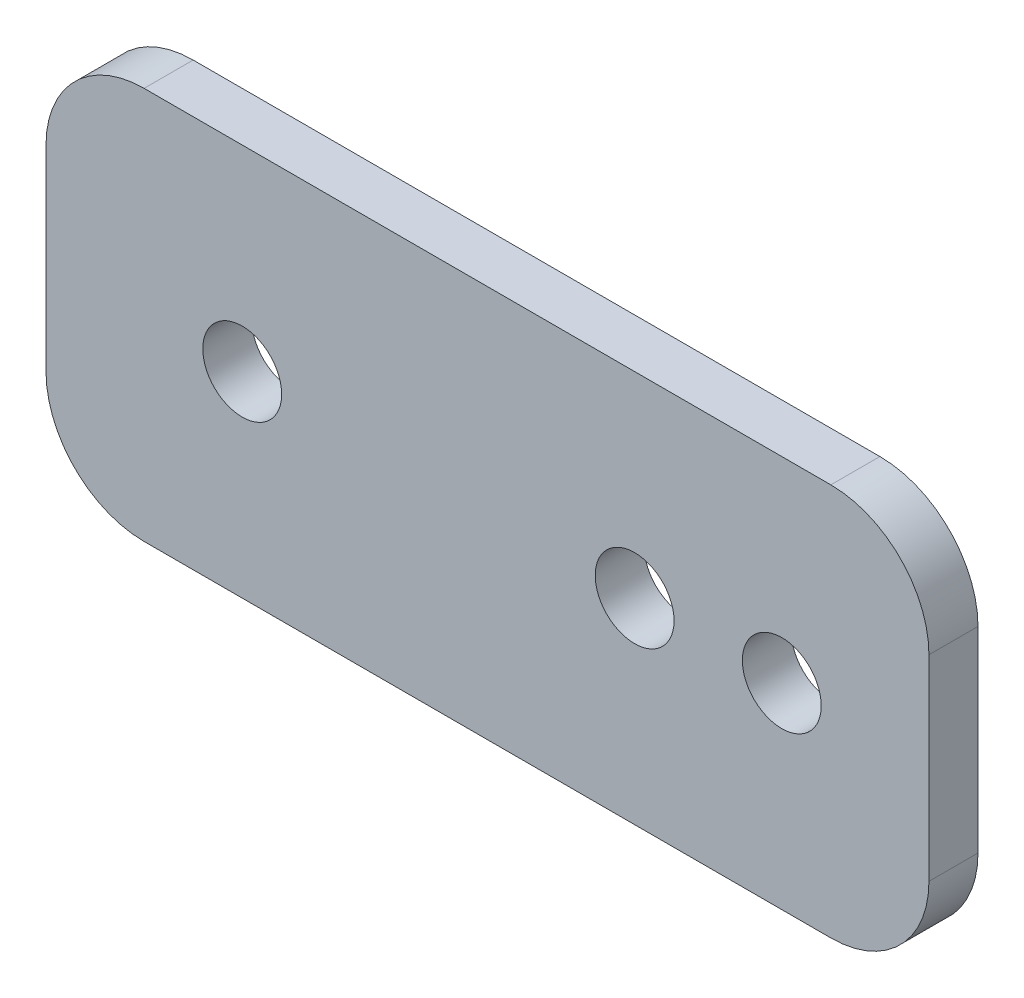
from build123d import *

# Parameters (mm, degrees)
SKETCH1_W           = 57.15
SKETCH1_H           = 25.4
SKETCH1_R           = 2.5527
BOSS_EXTRUDE1_DEPTH = 3.175
FILLET1_R           = 6.35


with BuildPart() as part:
    # Sketch1 → Boss-Extrude1 (new body)
    with BuildSketch(Plane.XY):
        with Locations((28.575, -12.7)):
            Rectangle(SKETCH1_W, SKETCH1_H)
        with Locations((12.7, -12.7)):
            Circle(SKETCH1_R, mode=Mode.SUBTRACT)
        with Locations((38.1, -12.7)):
            Circle(SKETCH1_R, mode=Mode.SUBTRACT)
        with Locations((47.625, -12.7)):
            Circle(SKETCH1_R, mode=Mode.SUBTRACT)
    extrude(amount=BOSS_EXTRUDE1_DEPTH)

    # Fillet1
    fillet1_edges = [part.edges().sort_by_distance(p)[0] for p in [
        (0, 0, 1.5875),
        (57.15, 0, 1.5875),
        (57.15, -25.4, 1.5875),
        (0, -25.4, 1.5875),
    ]]
    fillet(fillet1_edges, radius=FILLET1_R)


solid = part.part
